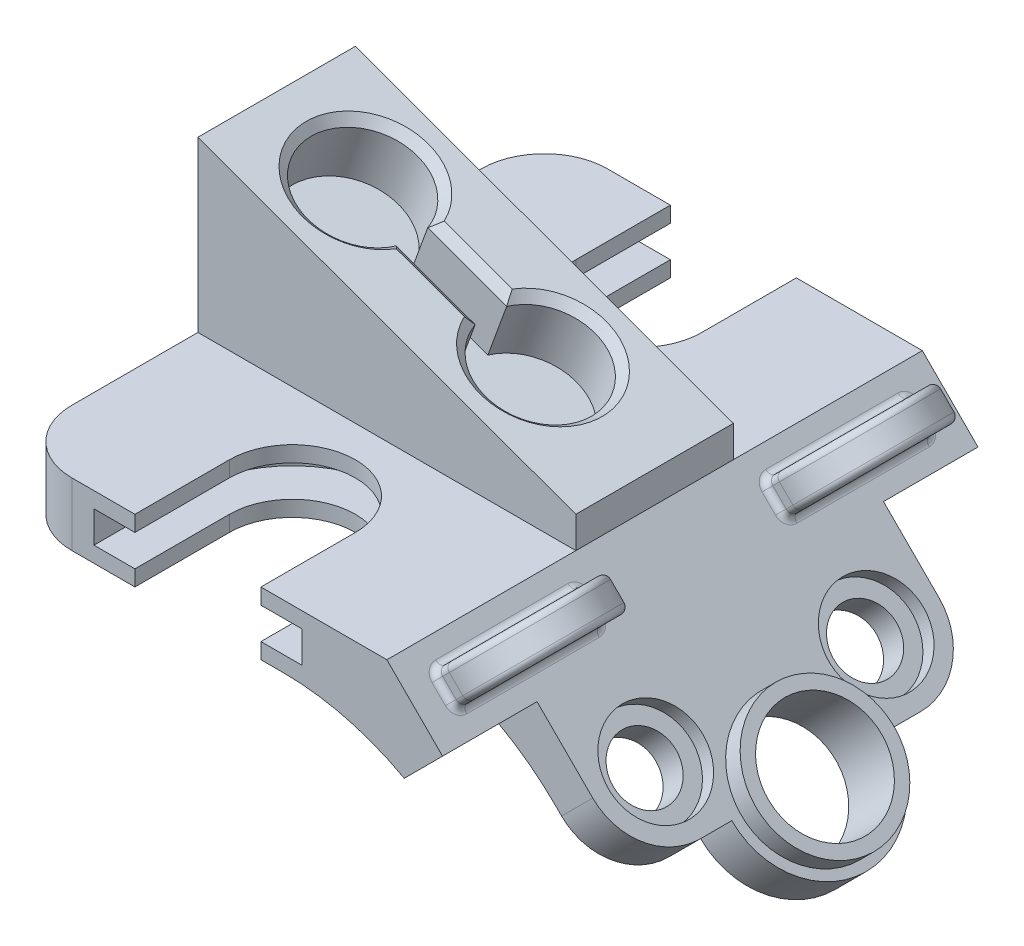
from build123d import *

# Parameters (mm, degrees)
BOSS_EXTRUDE1_DEPTH = 53.975
CUT_EXTRUDE1_DEPTH  = 140.411114894
CUT_EXTRUDE2_DEPTH  = 3.175
BOSS_EXTRUDE2_DEPTH = 15.875
CUT_EXTRUDE3_DEPTH  = 12.7
CHAMFER1_SIZE       = 1.651
CUT_EXTRUDE4_DEPTH  = 12.7
FILLET1_R           = 12.7
SKETCH9_R           = 6.35
CUT_EXTRUDE5_DEPTH  = 12.7
SKETCH10_R          = 9.525
CUT_EXTRUDE6_DEPTH  = 3.175
SKETCH11_R          = 13.97
BOSS_EXTRUDE3_DEPTH = 4.1275
SKETCH12_R          = 11.43
CUT_EXTRUDE7_DEPTH  = 124.457441957
SKETCH13_W          = 29.21
SKETCH13_H          = 6.35
BOSS_EXTRUDE4_DEPTH = 17.78
CUT_EXTRUDE8_DEPTH  = 131.033845412
FILLET3_R           = 1.905
FILLET4_R           = 1.27


with BuildPart() as part:
    # Sketch1 → Boss-Extrude1 (new, symmetric)
    with BuildSketch(Plane.XY):
        with BuildLine():
            Line((0, 0), (0, 12.7))
            Line((0, 12.7), (76.2, 12.7))
            Line((76.2, 12.7), (118.856216575, -29.956216575))
            Line((118.856216575, -29.956216575), (112.57003729, -36.24239586))
            Line((112.57003729, -36.24239586), (91.206616946, -14.878975516))
            ThreePointArc((91.206616946, -14.878975516), (74.725910826, -3.866919748), (55.285592462, 0))
            Line((55.285592462, 0), (0, 0))
        make_face()
    extrude(amount=BOSS_EXTRUDE1_DEPTH, both=True)

    # Sketch2 → Cut-Extrude1 (cut, through all)
    with BuildSketch(Plane(origin=(0, 12.7, 0), x_dir=(1, 0, 0), z_dir=(0, 1, 0))):
        with BuildLine():
            Line((25.4, 53.975), (25.4, 34.925))
            ThreePointArc((25.4, 34.925), (38.1, 22.225), (50.8, 34.925))
            Line((50.8, 34.925), (50.8, 53.975))
            Line((50.8, 53.975), (25.4, 53.975))
        make_face()
        with BuildLine():
            Line((25.4, -53.975), (50.8, -53.975))
            Line((50.8, -53.975), (50.8, -34.925))
            ThreePointArc((50.8, -34.925), (38.1, -22.225), (25.4, -34.925))
            Line((25.4, -34.925), (25.4, -53.975))
        make_face()
    extrude(amount=-CUT_EXTRUDE1_DEPTH, mode=Mode.SUBTRACT)

    # Sketch4 → Cut-Extrude2 (cut, symmetric)
    with BuildSketch(Plane(origin=(0, 6.35, 0), x_dir=(1, 0, 0), z_dir=(0, 1, 0))):
        with BuildLine():
            Line((59.055, -34.925), (59.055, -53.975))
            Line((59.055, -53.975), (17.145, -53.975))
            Line((17.145, -53.975), (17.145, -34.925))
            ThreePointArc((17.145, -34.925), (38.1, -13.97), (59.055, -34.925))
        make_face()
        with BuildLine():
            Line((17.145, 53.975), (17.145, 34.925))
            ThreePointArc((17.145, 34.925), (38.1, 13.97), (59.055, 34.925))
            Line((59.055, 34.925), (59.055, 53.975))
            Line((59.055, 53.975), (17.145, 53.975))
        make_face()
    extrude(amount=CUT_EXTRUDE2_DEPTH, both=True, mode=Mode.SUBTRACT)

    # Sketch5 → Boss-Extrude2 (add, symmetric)
    with BuildSketch(Plane.XY):
        Polygon((0, 12.7), (0, 46.784531851), (76.2, 19.05), (76.2, 12.7), align=None)
    extrude(amount=BOSS_EXTRUDE2_DEPTH, both=True)

    # Sketch6 → Cut-Extrude3 (cut)
    with BuildSketch(Plane(origin=(15.036258699, 41.31178125, 0), x_dir=(0.9396926207859106, -0.3420201433256628, 0), z_dir=(0.3420201433256627, 0.9396926207859105, 0))):
        with BuildLine():
            Line((13.631742372, 3.175), (30.56575305, 3.175))
            ThreePointArc((30.56575305, 3.175), (52.197747711, 0), (30.56575305, -3.175))
            Line((30.56575305, -3.175), (13.631742372, -3.175))
            ThreePointArc((13.631742372, -3.175), (-8.000252289, 0), (13.631742372, 3.175))
        make_face()
    extrude(amount=-CUT_EXTRUDE3_DEPTH, mode=Mode.SUBTRACT)

    # Chamfer1
    chamfer1_edges = [part.edges().sort_by_distance(p)[0] for p in [
        (7.518480659, 44.048028684, 0),
        (35.802288852, 33.75356439, 3.175),
        (64.086097045, 23.459100096, 0),
        (35.802288852, 33.75356439, -3.175),
    ]]
    chamfer(chamfer1_edges, length=CHAMFER1_SIZE)

    # Sketch7 → Cut-Extrude4 (cut)
    with BuildSketch(Plane(origin=(44.45, 44.45, 0), x_dir=(0, 0, -1), z_dir=(0.7071067811865483, 0.7071067811865468, 0))):
        with BuildLine():
            Line((-34.925, -60.776280605), (-53.975, -60.776280605))
            Line((-53.975, -60.776280605), (-53.975, -105.226280605))
            Line((-53.975, -105.226280605), (-8.3e-08, -105.226280605))
            ThreePointArc((-8.3e-08, -105.226280605), (-11.225320181, -100.576600727), (-15.875, -89.351280605))
            Line((-15.875, -89.351280605), (-34.925, -89.351280605))
            Line((-34.925, -89.351280605), (-34.925, -60.776280605))
        make_face()
        with BuildLine():
            ThreePointArc((15.875, -89.351280605), (11.225320122, -100.576600786), (-8.3e-08, -105.226280605))
            Line((-8.3e-08, -105.226280605), (53.975, -105.226280605))
            Line((53.975, -105.226280605), (53.975, -60.776280605))
            Line((53.975, -60.776280605), (34.925, -60.776280605))
            Line((34.925, -60.776280605), (34.925, -89.351280605))
            Line((34.925, -89.351280605), (15.875, -89.351280605))
        make_face()
    extrude(amount=-CUT_EXTRUDE4_DEPTH, mode=Mode.SUBTRACT)

    # Fillet1
    fillet1_edges = [part.edges().sort_by_distance(p)[0] for p in [
        (104.487806781, -21.873986066, 34.925),
        (104.487806781, -21.873986066, -34.925),
        (0, 6.35, 53.975),
        (0, 6.35, -53.975),
    ]]
    fillet(fillet1_edges, radius=FILLET1_R)

    # Sketch9 → Cut-Extrude5 (cut)
    with BuildSketch(Plane(origin=(44.45, 44.45, 0), x_dir=(0, 0, -1), z_dir=(0.7071067811865482, 0.7071067811865468, 0))):
        with Locations(Location((-22.225, -76.651280605, 0), (0, 0, 90))):
            Circle(SKETCH9_R)
        with Locations(Location((22.225, -76.651280605, 0), (0, 0, 90))):
            Circle(SKETCH9_R)
    extrude(amount=-CUT_EXTRUDE5_DEPTH, mode=Mode.SUBTRACT)

    # Sketch10 → Cut-Extrude6 (cut)
    with BuildSketch(Plane(origin=(44.45, 44.45, 0), x_dir=(0, 0, -1), z_dir=(0.7071067811865482, 0.7071067811865468, 0))):
        with Locations(Location((-22.225, -76.651280605, 0), (0, 0, 90))):
            Circle(SKETCH10_R)
        with Locations(Location((22.225, -76.651280605, 0), (0, 0, 90))):
            Circle(SKETCH10_R)
    extrude(amount=-CUT_EXTRUDE6_DEPTH, mode=Mode.SUBTRACT)

    # Sketch11 → Boss-Extrude3 (add, symmetric)
    with BuildSketch(Plane(origin=(44.45, 44.45, 0), x_dir=(0, 0, -1), z_dir=(0.7071067811865482, 0.7071067811865468, 0))):
        with Locations(Location((0, -89.351280605, 0), (0, 0, 270))):
            Circle(SKETCH11_R)
    extrude(amount=BOSS_EXTRUDE3_DEPTH, both=True)

    # Sketch12 → Cut-Extrude7 (cut, through all)
    with BuildSketch(Plane(origin=(47.368583239, 47.368583239, 0), x_dir=(0, 0, -1), z_dir=(0.7071067811865483, 0.7071067811865468, 0))):
        with Locations(Location((0, -89.351280605, 0), (0, 0, 90))):
            Circle(SKETCH12_R)
    extrude(amount=-CUT_EXTRUDE7_DEPTH, mode=Mode.SUBTRACT)

    # Sketch13 → Boss-Extrude4 (add)
    with BuildSketch(Plane(origin=(44.45, 44.45, 0), x_dir=(0, 0, -1), z_dir=(0.7071067811865482, 0.7071067811865468, 0))):
        with Locations((-33.274, -52.838780605)):
            Rectangle(SKETCH13_W, SKETCH13_H)
        with Locations((33.274, -52.838780605)):
            Rectangle(SKETCH13_W, SKETCH13_H)
    extrude(amount=BOSS_EXTRUDE4_DEPTH)

    # Sketch14 → Cut-Extrude8 (cut, through all)
    with BuildSketch(Plane(origin=(39.607724106, -39.607724106, 0), x_dir=(0, 0, -1), z_dir=(0.7071067811865468, -0.7071067811865483, 0))):
        with BuildLine():
            ThreePointArc((-33.274, 80.641792847), (-22.946705461, 76.364087387), (-18.669, 66.036792847))
            Line((-18.669, 66.036792847), (-18.669, 80.641792847))
            Line((-18.669, 80.641792847), (-33.274, 80.641792847))
        make_face()
        with BuildLine():
            Line((-47.879, 80.641792847), (-47.879, 66.036792847))
            ThreePointArc((-47.879, 66.036792847), (-43.601294539, 76.364087387), (-33.274, 80.641792847))
            Line((-33.274, 80.641792847), (-47.879, 80.641792847))
        make_face()
        with BuildLine():
            Line((-44.704, 66.036792847), (-21.844, 66.036792847))
            ThreePointArc((-21.844, 66.036792847), (-33.274, 77.466792847), (-44.704, 66.036792847))
        make_face()
        with BuildLine():
            Line((18.669, 80.641792847), (18.669, 66.036792847))
            ThreePointArc((18.669, 66.036792847), (22.946705461, 76.364087387), (33.274, 80.641792847))
            Line((33.274, 80.641792847), (18.669, 80.641792847))
        make_face()
        with BuildLine():
            Line((47.879, 80.641792847), (33.274, 80.641792847))
            ThreePointArc((33.274, 80.641792847), (43.601294539, 76.364087387), (47.879, 66.036792847))
            Line((47.879, 66.036792847), (47.879, 80.641792847))
        make_face()
        with BuildLine():
            ThreePointArc((21.844, 66.036792847), (33.274, 77.466792847), (44.704, 66.036792847))
            Line((44.704, 66.036792847), (21.844, 66.036792847))
        make_face()
    extrude(amount=-CUT_EXTRUDE8_DEPTH, mode=Mode.SUBTRACT)

    # Fillet3
    fillet3_edges = [part.edges().sort_by_distance(p)[0] for p in [
        (84.057724106, 9.332403955, -21.844),
        (84.057724106, 9.332403955, -44.704),
        (84.057724106, 9.332403955, 21.844),
        (84.057724106, 9.332403955, 44.704),
    ]]
    fillet(fillet3_edges, radius=FILLET3_R)

    # Fillet4
    fillet4_edges = [part.edges().sort_by_distance(p)[0] for p in [
        (81.812660076, 7.087339924, 18.669),
        (79.567596045, 9.332403955, 33.274),
        (81.812660076, 7.087339924, 47.879),
        (84.057724106, 4.842275894, 33.274),
        (81.812660076, 7.087339924, -47.879),
        (79.567596045, 9.332403955, -33.274),
        (81.812660076, 7.087339924, -18.669),
        (84.057724106, 4.842275894, -33.274),
        (85.180256121, 5.964807909, 18.669),
        (80.690128061, 10.45493597, 18.669),
        (85.180256121, 5.964807909, -47.879),
        (80.690128061, 10.45493597, -47.879),
        (96.630082675, 17.414634464, 33.274),
        (92.139954615, 21.904762524, 33.274),
        (92.139954615, 21.904762524, -33.274),
        (96.630082675, 17.414634464, -33.274),
        (85.180256121, 5.964807909, 47.879),
        (80.690128061, 10.45493597, 47.879),
        (85.180256121, 5.964807909, -18.669),
        (80.690128061, 10.45493597, -18.669),
    ]]
    fillet(fillet4_edges, radius=FILLET4_R)


solid = part.part
